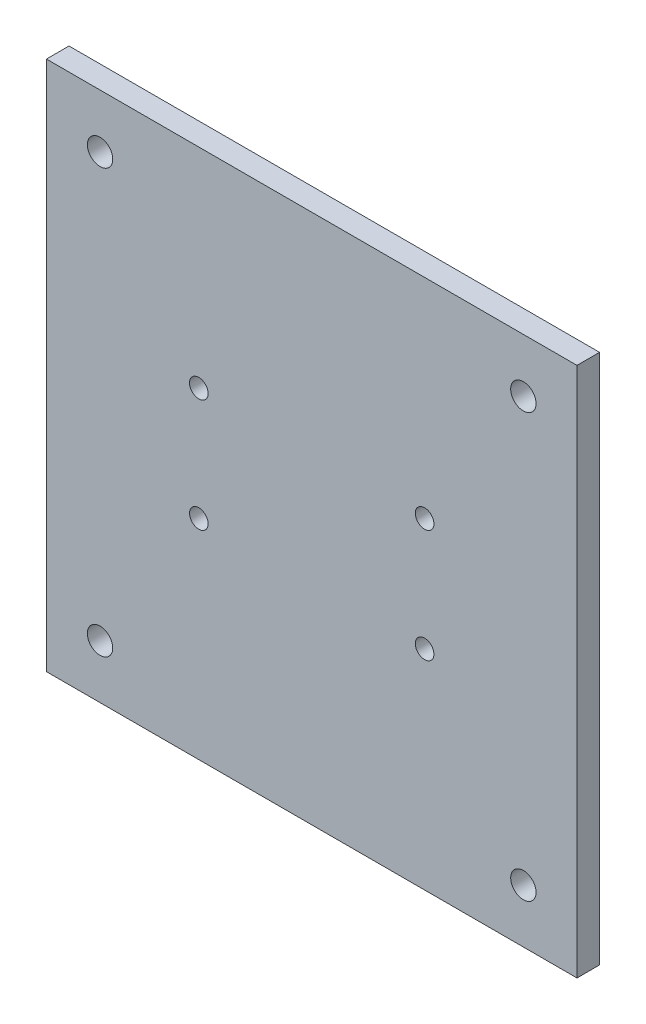
from build123d import *

# Parameters (mm, degrees)
SKETCH1_W           = 78
SKETCH1_H           = 45
SKETCH1_R           = 1.6
BOSS_EXTRUDE1_DEPTH = 4
SKETCH5_W           = 94
SKETCH5_H           = 94
SKETCH5_R           = 2.25
BOSS_EXTRUDE3_DEPTH = 4
SKETCH6_R           = 1.65
CUT_EXTRUDE1_DEPTH  = 5
CHAMFER1_SIZE       = 1.6


with BuildPart() as part:
    # Sketch1 → Boss-Extrude1 (new body)
    with BuildSketch(Plane.XY):
        with Locations((39, 22.5)):
            Rectangle(SKETCH1_W, SKETCH1_H)
        with Locations((19, 32.5)):
            Circle(SKETCH1_R, mode=Mode.SUBTRACT)
        with Locations((59, 32.5)):
            Circle(SKETCH1_R, mode=Mode.SUBTRACT)
        with Locations((59, 12.5)):
            Circle(SKETCH1_R, mode=Mode.SUBTRACT)
        with Locations((19, 12.5)):
            Circle(SKETCH1_R, mode=Mode.SUBTRACT)
    extrude(amount=BOSS_EXTRUDE1_DEPTH)

    # Sketch5 → Boss-Extrude3 (add)
    with BuildSketch(Plane.XY):
        with Locations((39, 22.5)):
            Rectangle(SKETCH5_W, SKETCH5_H)
        with Locations((1.5, 60)):
            Circle(SKETCH5_R, mode=Mode.SUBTRACT)
        with Locations((76.5, 60)):
            Circle(SKETCH5_R, mode=Mode.SUBTRACT)
        with Locations((76.5, -15)):
            Circle(SKETCH5_R, mode=Mode.SUBTRACT)
        with Locations((1.5, -15)):
            Circle(SKETCH5_R, mode=Mode.SUBTRACT)
    extrude(amount=BOSS_EXTRUDE3_DEPTH)

    # Sketch6 → Cut-Extrude1 (cut, through all)
    with BuildSketch(Plane(origin=(0, 0, 0), x_dir=(-1, 0, 0), z_dir=(0, 0, -1))):
        with Locations((-59, 32.5)):
            Circle(SKETCH6_R)
        with Locations((-59, 12.5)):
            Circle(SKETCH6_R)
        with Locations((-19, 12.5)):
            Circle(SKETCH6_R)
        with Locations((-19, 32.5)):
            Circle(SKETCH6_R)
    extrude(amount=-CUT_EXTRUDE1_DEPTH, mode=Mode.SUBTRACT)

    # Chamfer1
    chamfer1_edges = [part.edges().sort_by_distance(p)[0] for p in [
        (20.65, 32.5, 0),
        (20.65, 12.5, 0),
        (60.65, 12.5, 0),
        (60.65, 32.5, 0),
    ]]
    chamfer(chamfer1_edges, length=CHAMFER1_SIZE)


solid = part.part
